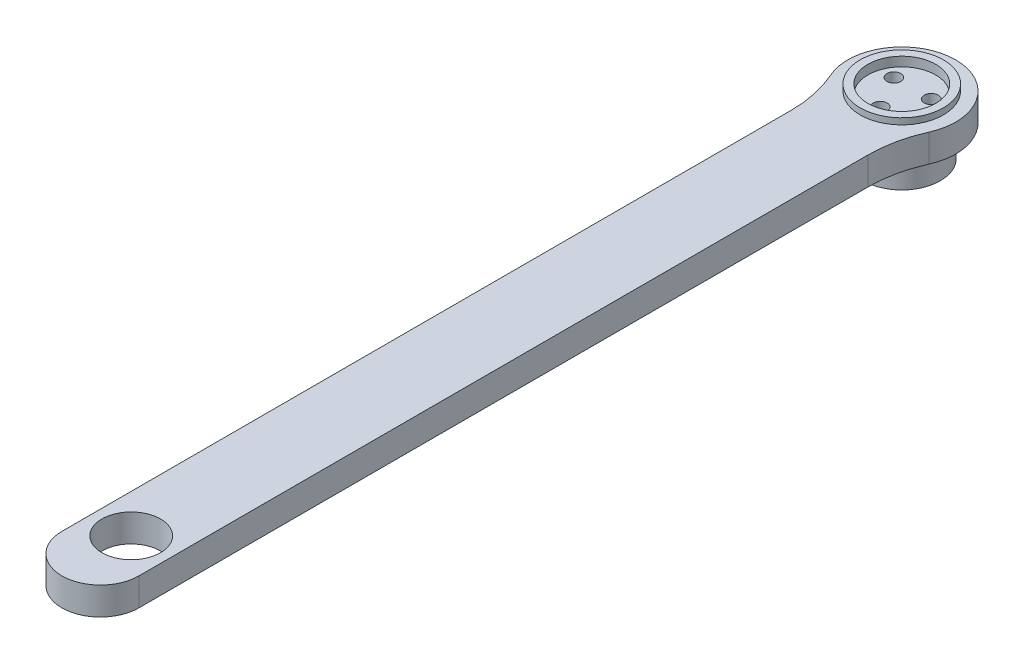
from build123d import *

# Parameters (mm, degrees)
EXTRUDE_1_DEPTH              = 9
SKETCH_3_R                   = 13.5
EXTRUDE_2_DEPTH              = 2
EXTRUDE_START                = 3
SKETCH_4_R                   = 13.5
EXTRUDE_3_DEPTH              = 3
SKETCH_5_R                   = 9.5
CUT_EXTRUDE_2_DEPTH          = 274.324898244
HOLE_WIZARD_M4_1_D           = 4.5
HOLE_WIZARD_M4_1_CBORE_D     = 8
HOLE_WIZARD_M4_1_CBORE_DEPTH = 4.4
PATTERN_CIRCULAR_1_COUNT     = 3
EXTRUDE_START_2              = 7
SKETCH_11_R                  = 12.5
SKETCH_11_R_2                = 4
EXTRUDE_4_DEPTH              = 7
SKETCH_13_R                  = 11
CUT_EXTRUDE_3_DEPTH          = 3
FILLET_1_R                   = 40


with BuildPart() as part:
    # 스케치1 → 보스-돌출1 (new body)
    with BuildSketch(Plane(origin=(0, 0, 0), x_dir=(1, 0, 0), z_dir=(0, 1, 0))):
        with BuildLine():
            Line((-12.5, -260), (-12.5, -12.247448714))
            ThreePointArc((-12.5, -12.247448714), (0, 17.5), (12.5, -12.247448714))
            Line((12.5, -12.247448714), (12.5, -260))
            ThreePointArc((12.5, -260), (0, -272.5), (-12.5, -260))
        make_face()
    extrude(amount=EXTRUDE_1_DEPTH)

    # 스케치3 → 보스-돌출2 (add)
    with BuildSketch(Plane(origin=(0, 9, 0), x_dir=(1, 0, 0), z_dir=(0, 1, 0))):
        Circle(SKETCH_3_R)
    extrude(amount=EXTRUDE_2_DEPTH)

    # 스케치4 → 보스-돌출3 (add)
    with BuildSketch(Plane.XZ.offset(EXTRUDE_START)):
        Circle(SKETCH_4_R)
    extrude(amount=-EXTRUDE_3_DEPTH)

    # 스케치5 → 컷-돌출2 (cut, through all)
    with BuildSketch(Plane(origin=(0, 9, 0), x_dir=(1, 0, 0), z_dir=(0, 1, 0))):
        with Locations((0, -250)):
            Circle(SKETCH_5_R)
    extrude(amount=-CUT_EXTRUDE_2_DEPTH, mode=Mode.SUBTRACT)

    # M4 육각 소켓 머리 캡 나사용 카운터보어1 (through all)
    with Locations(Plane(origin=(0, -3, 0), x_dir=(-1, 0, 0), z_dir=(0, -1, 0))):
        with Locations((0, -7)):
            hole_wizard_m4_1 = CounterBoreHole(HOLE_WIZARD_M4_1_D / 2, HOLE_WIZARD_M4_1_CBORE_D / 2, HOLE_WIZARD_M4_1_CBORE_DEPTH)

    # 원형 패턴1: M4 육각 소켓 머리 캡 나사용 카운터보어1 ×3 about axis
    pattern_circular_1_axis = Axis((0, 9, 0), (0, -1, 0))
    for i in range(1, PATTERN_CIRCULAR_1_COUNT):
        add(hole_wizard_m4_1.rotate(pattern_circular_1_axis, i * 360 / PATTERN_CIRCULAR_1_COUNT), mode=Mode.SUBTRACT)

    # 스케치11 → 보스-돌출4 (add)
    with BuildSketch(Plane.XZ.offset(3).offset(EXTRUDE_START_2)):
        Circle(SKETCH_11_R)
        with Locations((-6.062177826, -3.5)):
            Circle(SKETCH_11_R_2, mode=Mode.SUBTRACT)
        with Locations((6.062177826, -3.5)):
            Circle(SKETCH_11_R_2, mode=Mode.SUBTRACT)
        with Locations((0, 7)):
            Circle(SKETCH_11_R_2, mode=Mode.SUBTRACT)
    extrude(amount=-EXTRUDE_4_DEPTH)

    # 스케치13 → 컷-돌출3 (cut)
    with BuildSketch(Plane(origin=(0, 11, 0), x_dir=(1, 0, 0), z_dir=(0, 1, 0))):
        Circle(SKETCH_13_R)
    extrude(amount=-CUT_EXTRUDE_3_DEPTH, mode=Mode.SUBTRACT)

    # 필렛1
    fillet_1_edges = [part.edges().sort_by_distance(p)[0] for p in [
        (12.5, 4.5, 12.247448714),
        (-12.5, 4.5, 12.247448714),
    ]]
    fillet(fillet_1_edges, radius=FILLET_1_R)


solid = part.part
